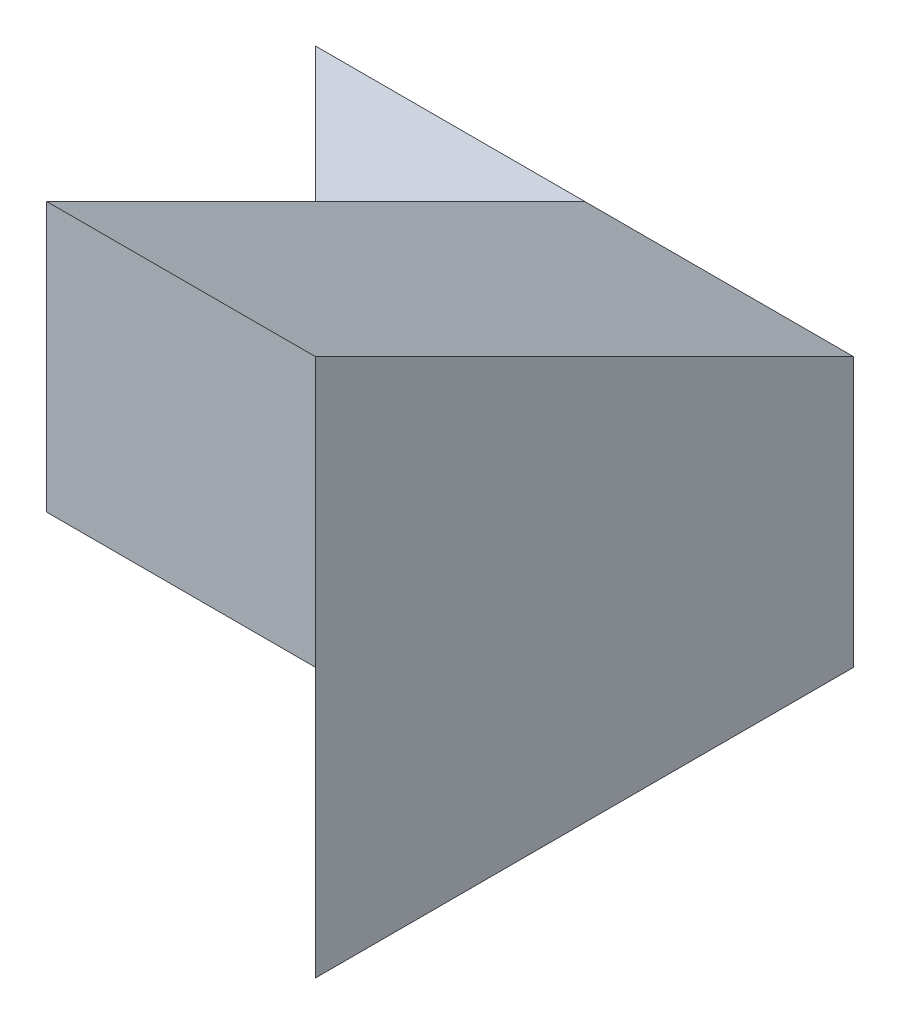
from build123d import *

# Parameters (mm, degrees)
SKETCH1_W            = 40
SKETCH1_H            = 40
BOSS_EXTRUDE1_DEPTH  = 40
SKETCH2_W            = 20
SKETCH2_H            = 20
CUT_EXTRUDE1_DEPTH   = 40
CUT_EXTRUDE2_DEPTH   = 40
CUT_EXTRUDE6_DEPTH   = 40
CUT_EXTRUDE7_DEPTH   = 19.999
SKETCH7_W            = 19.998
SKETCH7_H            = 19.999
CUT_EXTRUDE8_DEPTH   = 19.999
SKETCH8_W            = 19.999
SKETCH8_H            = 19.999
CUT_EXTRUDE9_DEPTH   = 19.999
SKETCH11_W           = 28.28144282
SKETCH11_H           = 19.999
BOSS_EXTRUDE9_DEPTH  = 0.0009
BOSS_EXTRUDE10_DEPTH = 20
SKETCH14_W           = 57
SKETCH14_H           = 20
CUT_EXTRUDE11_DEPTH  = 20


with BuildPart() as part:
    # Sketch1 → Boss-Extrude1 (new body)
    with BuildSketch(Plane.XY):
        with Locations((20, 20)):
            Rectangle(SKETCH1_W, SKETCH1_H)
    extrude(amount=BOSS_EXTRUDE1_DEPTH)

    # Sketch2 → Cut-Extrude1 (cut)
    with BuildSketch(Plane.XY.offset(40)):
        with Locations((10, 30)):
            Rectangle(SKETCH2_W, SKETCH2_H)
    extrude(amount=-CUT_EXTRUDE1_DEPTH, mode=Mode.SUBTRACT)

    # Sketch3 → Cut-Extrude2 (cut)
    with BuildSketch(Plane.ZY.offset(-20)):
        Polygon((0, 20), (40, 40), (0, 40), align=None)
    extrude(amount=-CUT_EXTRUDE2_DEPTH, mode=Mode.SUBTRACT)

    # Sketch4 → Cut-Extrude6 (cut)
    with BuildSketch(Plane(origin=(0, 0, 0), x_dir=(1, 0, 0), z_dir=(0, 1, 0))):
        Polygon((0, 0), (20, -20), (20, -40), (0, -40), align=None)
    extrude(amount=CUT_EXTRUDE6_DEPTH, mode=Mode.SUBTRACT)

    # Sketch6 → Cut-Extrude7 (cut)
    with BuildSketch(Plane(origin=(0, 0, 0), x_dir=(-1, 0, 0), z_dir=(0, -1, 0))):
        Polygon((-20.001, -39.9999), (-39.999, -39.9999), (-20.001, -20.0019), align=None)
    extrude(amount=-CUT_EXTRUDE7_DEPTH, mode=Mode.SUBTRACT)

    # Sketch7 → Cut-Extrude8 (cut)
    with BuildSketch(Plane(origin=(20.001, 0, 0), x_dir=(0, 0, -1), z_dir=(1, 0, 0))):
        with Locations((-30.0009, 9.9995)):
            Rectangle(SKETCH7_W, SKETCH7_H)
    extrude(amount=-CUT_EXTRUDE8_DEPTH, mode=Mode.SUBTRACT)

    # Sketch8 → Cut-Extrude9 (cut)
    with BuildSketch(Plane(origin=(0, 0, 39.9999), x_dir=(-1, 0, 0), z_dir=(0, 0, -1))):
        with Locations((-29.9995, 9.9995)):
            Rectangle(SKETCH8_W, SKETCH8_H)
    extrude(amount=-CUT_EXTRUDE9_DEPTH, mode=Mode.SUBTRACT)

    # Sketch11 → Boss-Extrude9 (add)
    with BuildSketch(Plane(origin=(-0.00045, 0, 0.00045), x_dir=(0.707106781, 0, 0.707106781), z_dir=(-0.707106781, 0, 0.707106781))):
        with Locations((42.427043267, 9.9995)):
            Rectangle(SKETCH11_W, SKETCH11_H)
    extrude(amount=BOSS_EXTRUDE9_DEPTH)

    # Sketch13 → Boss-Extrude10 (add)
    with BuildSketch(Plane(origin=(0, 0, 0), x_dir=(-1, 0, 0), z_dir=(0, -1, 0))):
        Polygon((-20.001, -20.0019), (-20.000363604, -20.002536396), (-20, -20.0019), align=None)
    extrude(amount=-BOSS_EXTRUDE10_DEPTH)

    # Sketch14 → Cut-Extrude11 (cut)
    with BuildSketch(Plane(origin=(0, 0, 0), x_dir=(0.707106781, 0, 0.707106781), z_dir=(-0.707106781, 0, 0.707106781))):
        with Locations((28.5, 10)):
            Rectangle(SKETCH14_W, SKETCH14_H)
    extrude(amount=CUT_EXTRUDE11_DEPTH, mode=Mode.SUBTRACT)


solid = part.part
